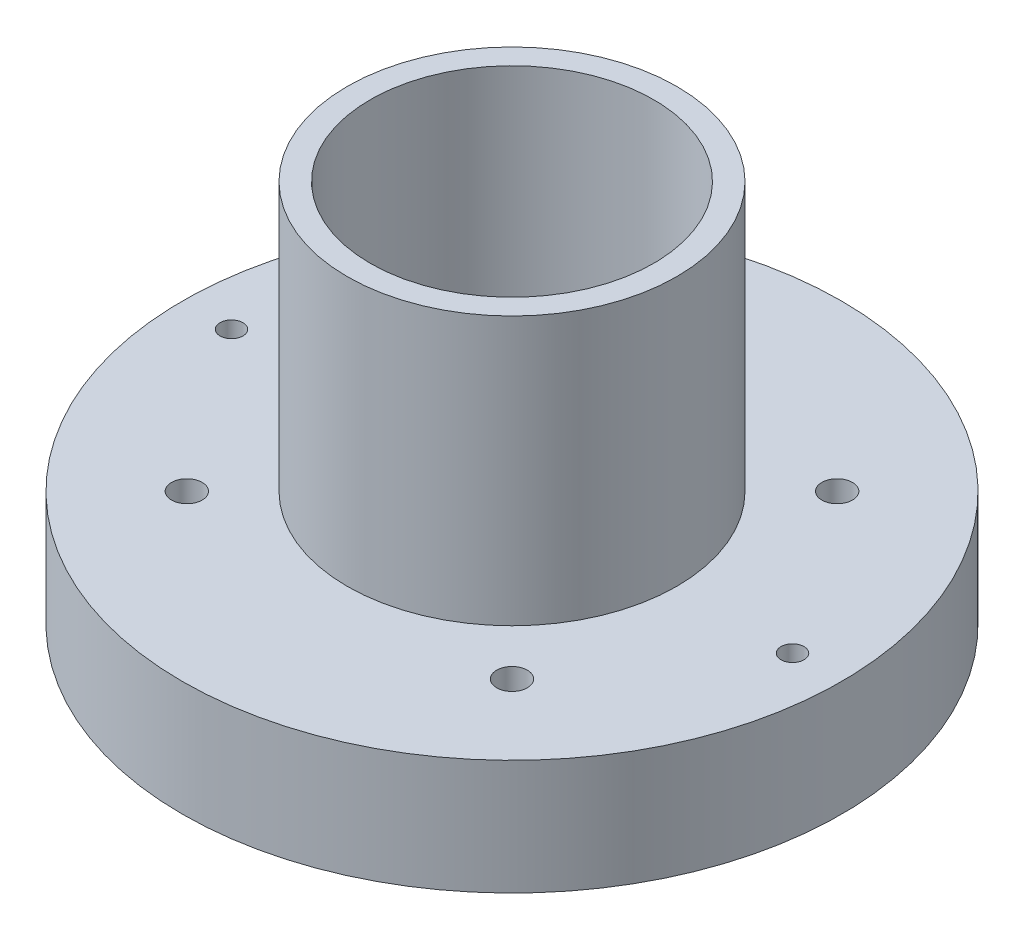
from build123d import *

# Parameters (mm, degrees)
SKETCH1_R             = 43
BOSS_EXTRUDE1_DEPTH   = 30
SKETCH6_R             = 25
CUT_EXTRUDE4_DEPTH    = 20
SKETCH10_R            = 21.5
SKETCH10_R_2          = 18.5
BOSS_EXTRUDE2_DEPTH   = 35
CUT_EXTRUDE6_DEPTH    = 31
F_3_0MM_DOWEL_HOLE1_D = 3
F_4_0MM_DOWEL_HOLE2_D = 4
SKETCH27_R            = 51.993622625
CUT_EXTRUDE7_DEPTH    = 15


with BuildPart() as part:
    # Sketch1 → Boss-Extrude1 (new body)
    with BuildSketch(Plane(origin=(0, 0, 0), x_dir=(1, 0, 0), z_dir=(0, 1, 0))):
        Circle(SKETCH1_R)
    extrude(amount=BOSS_EXTRUDE1_DEPTH)

    # Sketch6 → Cut-Extrude4 (cut)
    with BuildSketch(Plane.XZ):
        Circle(SKETCH6_R)
    extrude(amount=-CUT_EXTRUDE4_DEPTH, mode=Mode.SUBTRACT)

    # Sketch10 → Boss-Extrude2 (add)
    with BuildSketch(Plane(origin=(0, 30, 0), x_dir=(1, 0, 0), z_dir=(0, 1, 0))):
        Circle(SKETCH10_R)
        Circle(SKETCH10_R_2, mode=Mode.SUBTRACT)
    extrude(amount=BOSS_EXTRUDE2_DEPTH)

    # Sketch12 → Cut-Extrude6 (cut, through all)
    with BuildSketch(Plane(origin=(0, 30, 0), x_dir=(1, 0, 0), z_dir=(0, 1, 0))):
        with BuildLine():
            Line((-9.5, 6), (9.5, 6))
            ThreePointArc((9.5, 6), (15.5, 0), (9.5, -6))
            Line((9.5, -6), (-9.5, -6))
            ThreePointArc((-9.5, -6), (-15.5, 0), (-9.5, 6))
        make_face()
    extrude(amount=-CUT_EXTRUDE6_DEPTH, mode=Mode.SUBTRACT)

    # Ø3.0mm Dowel Hole1 (through all)
    with Locations(Plane(origin=(0, 30, 0), x_dir=(1, 0, 0), z_dir=(0, 1, 0))):
        with Locations((-36.6, 0), (36.6, 0)):
            Hole(F_3_0MM_DOWEL_HOLE1_D / 2)

    # Ø4.0mm Dowel Hole2 (through all)
    with Locations(Plane(origin=(0, 0, 0), x_dir=(-1, 0, 0), z_dir=(0, -1, 0))):
        with Locations((-21.213203436, -21.213203436), (21.213203436, -21.213203436), (-21.213203436, 21.213203436), (21.213203436, 21.213203436)):
            Hole(F_4_0MM_DOWEL_HOLE2_D / 2)

    # Sketch27 → Cut-Extrude7 (cut)
    with BuildSketch(Plane.XZ):
        Circle(SKETCH27_R)
    extrude(amount=-CUT_EXTRUDE7_DEPTH, mode=Mode.SUBTRACT)


solid = part.part
